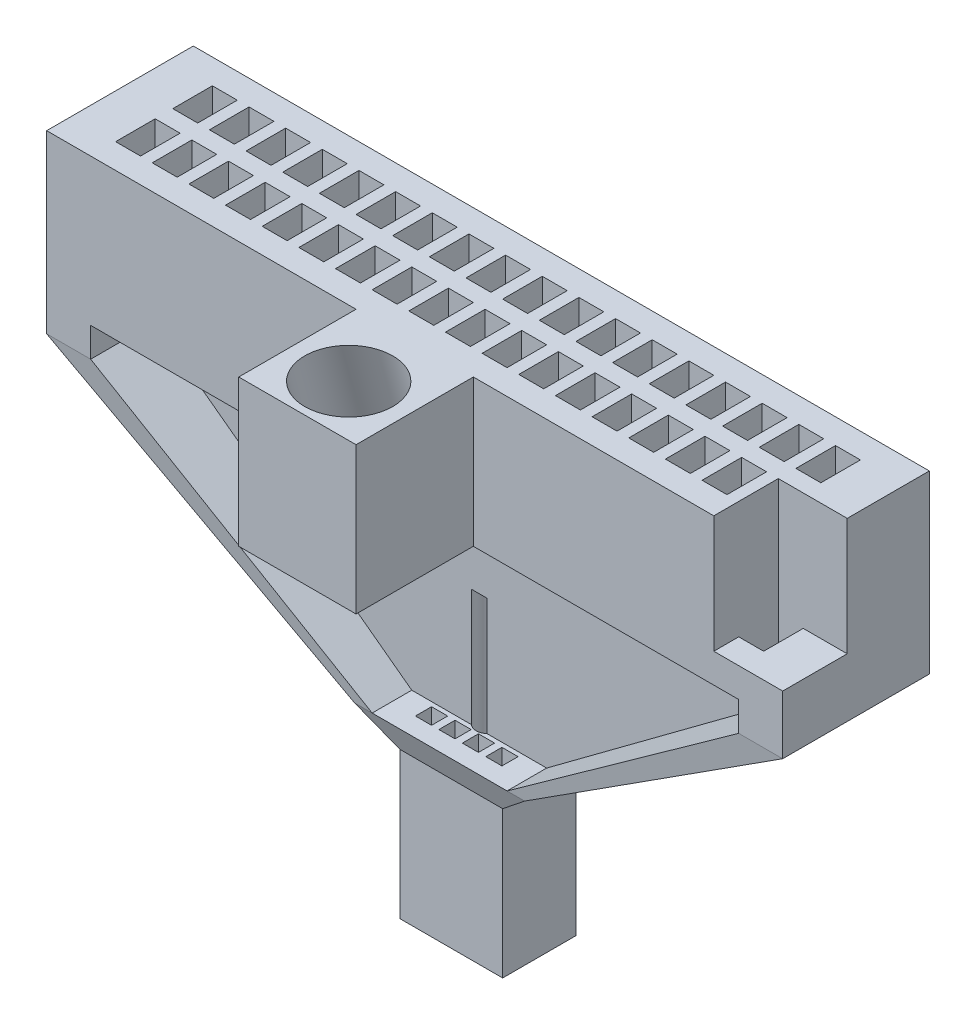
from build123d import *

# Parameters (mm, degrees)
MAIN_BLOCK_W             = 12.7508
MAIN_BLOCK_H             = 2.54
WELL_BLOCK_DEPTH         = 2.54
TOP_HOLES_W              = 0.4318
TOP_HOLES_H              = 0.6858
OMNETICS_WELLS_DEPTH     = 2.54
SKETCH8_W                = 0.762
SKETCH8_H                = 2.54
SUPPORTBEAM1_DEPTH       = 0.508
SKETCH10_W               = 0.762
SKETCH10_H               = 2.54
SUPPORTBEAM2_DEPTH       = 0.508
SKETCH7_W                = 0.3048
SKETCH7_H                = 1.77800034
SKETCH5_W                = 11.226700613
SKETCH5_H                = 0.3048
WALL_DIVIDER_DEPTH       = 0.508
SKETCH6_W                = 2.336782461
SKETCH6_H                = 0.3048
SKETCH12_W               = 2.9464
SKETCH12_H               = 1.77800034
SKETCH13_W               = 1.778
SKETCH13_H               = 1.27
SKETCH13_3_W             = 1.778
SKETCH13_3_H             = 1.27
TETRODE_FUNNEL_DEPTH     = 2.54
SKETCH17_W               = 1.1938
SKETCH17_H               = 1.1176
GROUND_WIRE_HOLE_DEPTH   = 2.032
SKETCH19_R               = 0.2032
FIBER_OPTIC_HOLE_DEPTH   = 5.08
SKETCH20_W               = 2.032
SKETCH20_H               = 2.54
FIBER_OPTIC_HOLDER_DEPTH = 2.032
SKETCH24_R               = 0.762
SKETCH25_R               = 0.762
TETRODE_SKETCH_W         = 0.2794
TETRODE_SKETCH_H         = 0.2794
CUT_EXTRUDE2_DEPTH       = 3.302


with BuildPart() as part:
    # main_block → well_block (new body)
    with BuildSketch(Plane(origin=(0, 0, 0), x_dir=(1, 0, 0), z_dir=(0, 1, 0))):
        with Locations((0.756592766, -0.05080017)):
            Rectangle(MAIN_BLOCK_W, MAIN_BLOCK_H)
    extrude(amount=-WELL_BLOCK_DEPTH)

    # top_holes → omnetics_wells (cut)
    with BuildSketch(Plane(origin=(0, 0, 0), x_dir=(1, 0, 0), z_dir=(0, 1, 0))):
        with Locations((6.154092766, 0.44449983)):
            Rectangle(TOP_HOLES_W, TOP_HOLES_H)
        with Locations((5.519098613, 0.44449983)):
            Rectangle(TOP_HOLES_W, TOP_HOLES_H)
        with Locations((4.884104459, 0.44449983)):
            Rectangle(TOP_HOLES_W, TOP_HOLES_H)
        with Locations((4.249110305, 0.44449983)):
            Rectangle(TOP_HOLES_W, TOP_HOLES_H)
        with Locations((3.614116151, 0.44449983)):
            Rectangle(TOP_HOLES_W, TOP_HOLES_H)
        with Locations((2.979121998, 0.44449983)):
            Rectangle(TOP_HOLES_W, TOP_HOLES_H)
        with Locations((2.344127844, 0.44449983)):
            Rectangle(TOP_HOLES_W, TOP_HOLES_H)
        with Locations((1.70913369, 0.44449983)):
            Rectangle(TOP_HOLES_W, TOP_HOLES_H)
        with Locations((1.074139537, 0.44449983)):
            Rectangle(TOP_HOLES_W, TOP_HOLES_H)
        with Locations((0.439145383, 0.44449983)):
            Rectangle(TOP_HOLES_W, TOP_HOLES_H)
        with Locations((-0.195848771, 0.44449983)):
            Rectangle(TOP_HOLES_W, TOP_HOLES_H)
        with Locations((-0.830842925, 0.44449983)):
            Rectangle(TOP_HOLES_W, TOP_HOLES_H)
        with Locations((-1.465837078, 0.44449983)):
            Rectangle(TOP_HOLES_W, TOP_HOLES_H)
        with Locations((-2.100831232, 0.44449983)):
            Rectangle(TOP_HOLES_W, TOP_HOLES_H)
        with Locations((-2.735825386, 0.44449983)):
            Rectangle(TOP_HOLES_W, TOP_HOLES_H)
        with Locations((-3.370819539, 0.44449983)):
            Rectangle(TOP_HOLES_W, TOP_HOLES_H)
        with Locations((-4.005813693, 0.44449983)):
            Rectangle(TOP_HOLES_W, TOP_HOLES_H)
        with Locations((-4.640807847, 0.44449983)):
            Rectangle(TOP_HOLES_W, TOP_HOLES_H)
        with Locations((5.519098613, -0.54610017)):
            Rectangle(TOP_HOLES_W, TOP_HOLES_H)
        with Locations((4.884104459, -0.54610017)):
            Rectangle(TOP_HOLES_W, TOP_HOLES_H)
        with Locations((4.249110305, -0.54610017)):
            Rectangle(TOP_HOLES_W, TOP_HOLES_H)
        with Locations((3.614116151, -0.54610017)):
            Rectangle(TOP_HOLES_W, TOP_HOLES_H)
        with Locations((2.979121998, -0.54610017)):
            Rectangle(TOP_HOLES_W, TOP_HOLES_H)
        with Locations((2.344127844, -0.54610017)):
            Rectangle(TOP_HOLES_W, TOP_HOLES_H)
        with Locations((1.70913369, -0.54610017)):
            Rectangle(TOP_HOLES_W, TOP_HOLES_H)
        with Locations((1.074139537, -0.54610017)):
            Rectangle(TOP_HOLES_W, TOP_HOLES_H)
        with Locations((0.439145383, -0.54610017)):
            Rectangle(TOP_HOLES_W, TOP_HOLES_H)
        with Locations((-0.195848771, -0.54610017)):
            Rectangle(TOP_HOLES_W, TOP_HOLES_H)
        with Locations((-0.830842925, -0.54610017)):
            Rectangle(TOP_HOLES_W, TOP_HOLES_H)
        with Locations((-1.465837078, -0.54610017)):
            Rectangle(TOP_HOLES_W, TOP_HOLES_H)
        with Locations((-2.100831232, -0.54610017)):
            Rectangle(TOP_HOLES_W, TOP_HOLES_H)
        with Locations((-2.735825386, -0.54610017)):
            Rectangle(TOP_HOLES_W, TOP_HOLES_H)
        with Locations((-3.370819539, -0.54610017)):
            Rectangle(TOP_HOLES_W, TOP_HOLES_H)
        with Locations((-4.005813693, -0.54610017)):
            Rectangle(TOP_HOLES_W, TOP_HOLES_H)
        with Locations((-4.640807847, -0.54610017)):
            Rectangle(TOP_HOLES_W, TOP_HOLES_H)
        with Locations((6.154092766, -0.54610017)):
            Rectangle(TOP_HOLES_W, TOP_HOLES_H)
    extrude(amount=-OMNETICS_WELLS_DEPTH, mode=Mode.SUBTRACT)

    # Sketch8 → supportbeam1 (add)
    with BuildSketch(Plane.XZ.offset(2.54)):
        with Locations((-5.237707847, 0.05080017)):
            Rectangle(SKETCH8_W, SKETCH8_H)
    extrude(amount=SUPPORTBEAM1_DEPTH)

    # Sketch10 → supportbeam2 (add)
    with BuildSketch(Plane.XZ.offset(2.54)):
        with Locations((6.750992766, 0.05080017)):
            Rectangle(SKETCH10_W, SKETCH10_H)
    extrude(amount=SUPPORTBEAM2_DEPTH)

    # Sketch9 → section 0 of arm1
    with BuildSketch(Plane(origin=(0, -6.35, 0), x_dir=(1, 0, 0), z_dir=(0, 1, 0)), mode=Mode.PRIVATE) as arm1_s0:
        Polygon((1.92503369, -0.88900017), (1.924934303, 0.88900017), (2.229734303, 0.889017208), (2.22983369, -0.888983133), align=None)
    # loft up to a face of the part (arm1)
    loft([arm1_s0.sketch, part.faces().sort_by_distance((6.750992766, -3.048, 0.05080017))[0]])

    # Sketch7 → section 0 of arm2
    with BuildSketch(Plane(origin=(0, -6.35, 0), x_dir=(1, 0, 0), z_dir=(0, 1, 0)), mode=Mode.PRIVATE) as arm2_s0:
        with Locations((-0.564148771, 0)):
            Rectangle(SKETCH7_W, SKETCH7_H)
    # loft up to a face of the part (arm2)
    loft([arm2_s0.sketch, part.faces().sort_by_distance((-5.237707847, -3.048, 0.05080017))[0]])

    # Sketch5 → wall_divider (add)
    with BuildSketch(Plane.XZ.offset(2.54)):
        with Locations((0.75664246, 0.05080017)):
            Rectangle(SKETCH5_W, SKETCH5_H)
    extrude(amount=WALL_DIVIDER_DEPTH)

    # Sketch6 → section 1 of wall_divider2
    with BuildSketch(Plane(origin=(0, -6.35, 0), x_dir=(1, 0, 0), z_dir=(0, 1, 0)), mode=Mode.PRIVATE) as wall_divider2_s1:
        with Locations((0.756642459, -0.05080017)):
            Rectangle(SKETCH6_W, SKETCH6_H)
    # loft from a face of the part (wall_divider2)
    loft([part.faces().sort_by_distance((0.75664246, -3.048, 0.05080017))[0], wall_divider2_s1.sketch])

    # Sketch12 → exit_base section 0
    with BuildSketch(Plane(origin=(0, -6.35, 0), x_dir=(1, 0, 0), z_dir=(0, 1, 0))):
        with Locations((0.756651229, 0)):
            Rectangle(SKETCH12_W, SKETCH12_H)
    # Sketch13 → exit_base section 1
    with BuildSketch(Plane(origin=(0, -6.858, 0), x_dir=(1, 0, 0), z_dir=(0, 1, 0))):
        with Locations((0.756639537, -0.050800172)):
            Rectangle(SKETCH13_W, SKETCH13_H)
    loft()

    # Sketch13_3 → tetrode_funnel (add)
    with BuildSketch(Plane(origin=(0, -6.858, 0), x_dir=(1, 0, 0), z_dir=(0, 1, 0))):
        with Locations((0.756639537, -0.050800172)):
            Rectangle(SKETCH13_3_W, SKETCH13_3_H)
    extrude(amount=-TETRODE_FUNNEL_DEPTH)

    # Sketch17 → ground_wire_hole (cut)
    with BuildSketch(Plane(origin=(0, 0, 0), x_dir=(1, 0, 0), z_dir=(0, 1, 0))):
        with Locations((6.535092766, -0.76200017)):
            Rectangle(SKETCH17_W, SKETCH17_H)
    extrude(amount=-GROUND_WIRE_HOLE_DEPTH, mode=Mode.SUBTRACT)

    # Sketch19 → fiber_optic_hole (cut)
    with BuildSketch(Plane.XZ.offset(9.398)):
        with Locations((0.756639537, 0.050800172)):
            Circle(SKETCH19_R)
    extrude(amount=-FIBER_OPTIC_HOLE_DEPTH, mode=Mode.SUBTRACT)

    # Sketch20 → fiber_optic_holder (add)
    with BuildSketch(Plane.XY.offset(1.32080017)):
        with Locations((0.756592766, -1.27)):
            Rectangle(SKETCH20_W, SKETCH20_H)
    extrude(amount=FIBER_OPTIC_HOLDER_DEPTH)

    # Sketch24 → optic_holder_hole section 0
    with BuildSketch(Plane.XZ.offset(2.54)):
        with Locations((0.760600593, 1.77800017)):
            Circle(SKETCH24_R)
    # Sketch25 → optic_holder_hole section 1
    with BuildSketch(Plane(origin=(0, 0, 0), x_dir=(1, 0, 0), z_dir=(0, 1, 0))):
        with Locations((0.756592766, -2.46380017)):
            Circle(SKETCH25_R)
    loft(mode=Mode.SUBTRACT)

    # tetrode_sketch → Cut-Extrude2 (cut)
    with BuildSketch(Plane.XZ.offset(9.398)):
        with Locations((1.366239537, 0.419100172)):
            Rectangle(TETRODE_SKETCH_W, TETRODE_SKETCH_H)
        with Locations((0.959839537, 0.419100172)):
            Rectangle(TETRODE_SKETCH_W, TETRODE_SKETCH_H)
        with Locations((0.553439537, 0.419100172)):
            Rectangle(TETRODE_SKETCH_W, TETRODE_SKETCH_H)
        with Locations((0.147039537, 0.419100172)):
            Rectangle(TETRODE_SKETCH_W, TETRODE_SKETCH_H)
        with Locations((1.366239537, -0.317499828)):
            Rectangle(TETRODE_SKETCH_W, TETRODE_SKETCH_H)
        with Locations((0.959839537, -0.317499828)):
            Rectangle(TETRODE_SKETCH_W, TETRODE_SKETCH_H)
        with Locations((0.553439537, -0.317499828)):
            Rectangle(TETRODE_SKETCH_W, TETRODE_SKETCH_H)
        with Locations((0.147039537, -0.317499828)):
            Rectangle(TETRODE_SKETCH_W, TETRODE_SKETCH_H)
    extrude(amount=-CUT_EXTRUDE2_DEPTH, mode=Mode.SUBTRACT)


solid = part.part
